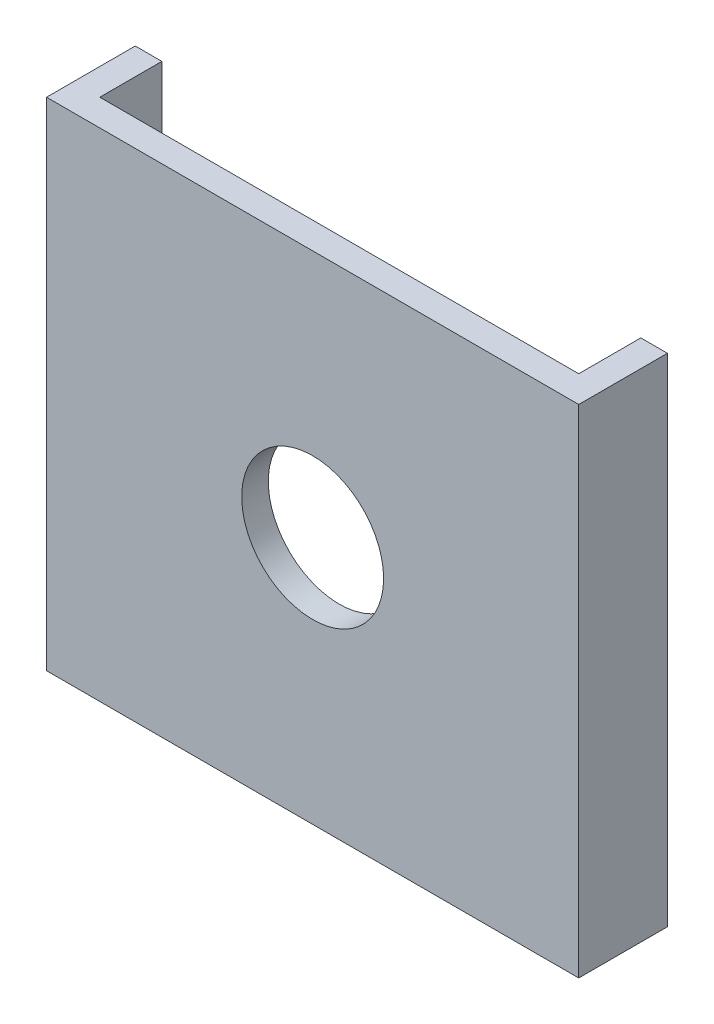
from build123d import *

# Parameters (mm, degrees)
EXTRUDE_1_DEPTH     = 28
EXTRUDE_2_DEPTH     = 1.5
SKETCH_3_R          = 1.55
CUT_EXTRUDE_1_DEPTH = 1.5
SKETCH_4_R          = 4
CUT_EXTRUDE_2_DEPTH = 1.5


with BuildPart() as part:
    # 草图1 → 凸台-拉伸1 (new body)
    with BuildSketch(Plane(origin=(0, 0, 0), x_dir=(1, 0, 0), z_dir=(0, 1, 0))):
        Polygon((-15, 0), (15, 0), (15, 5), (13.5, 5), (13.5, 1.5), (-13.5, 1.5), (-13.5, 5), (-15, 5), align=None)
    extrude(amount=EXTRUDE_1_DEPTH)

    # 草图4 → 切除-拉伸2 (cut)
    with BuildSketch(Plane.XY):
        with Locations((0, 14)):
            Circle(SKETCH_4_R)
    extrude(amount=-CUT_EXTRUDE_2_DEPTH, mode=Mode.SUBTRACT)


with BuildPart() as body_2:
    # 草图2 → 凸台-拉伸2 (new body)
    with BuildSketch(Plane.ZY.offset(15)):
        with BuildLine():
            Line((-8, 19), (-5, 19))
            Line((-5, 19), (-5, 9))
            Line((-5, 9), (-8, 9))
            ThreePointArc((-8, 9), (-13, 14), (-8, 19))
        make_face()
    extrude(amount=-EXTRUDE_2_DEPTH)

    # 草图3 → 切除-拉伸1 (cut)
    with BuildSketch(Plane(origin=(-13.5, 0, 0), x_dir=(0, 0, -1), z_dir=(1, 0, 0))):
        with Locations((8, 14)):
            Circle(SKETCH_3_R)
    extrude(amount=-CUT_EXTRUDE_1_DEPTH, mode=Mode.SUBTRACT)


solid = Compound([part.part, body_2.part])
